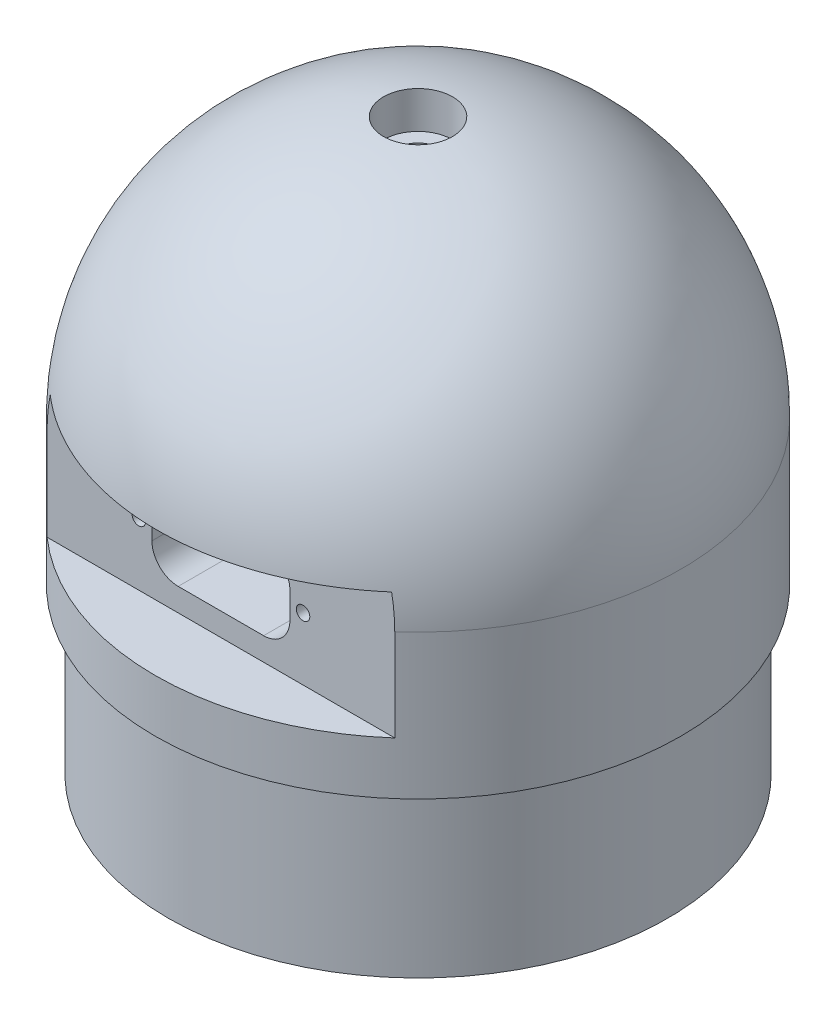
from build123d import *

# Parameters (mm, degrees)
ESQUISSE1_R                  = 40
BOSS_EXTRU_1_DEPTH           = 87
CONG_1_R                     = 40
ESQUISSE2_OUTSIDE_W          = 110.544
ESQUISSE2_OUTSIDE_H          = 110.544
ESQUISSE2_OUTSIDE_R          = 38
ENL_V_MAT_EXTRU_1_DEPTH      = 25
ENL_V_START                  = 40
ESQUISSE3_W                  = 76
ESQUISSE3_H                  = 19
ENL_V_MAT_EXTRU_2_DEPTH      = 10
ENL_V_MAT_EXTRU_3_DEPTH      = 20
ENL_V_MAT_EXTRU_4_DEPTH      = 68
ENL_V_MAT_EXTRU_5_REACH      = 21
ENL_V_MAT_EXTRU_5_END_RADIUS = 40
ESQUISSE6_R                  = 3.1
ESQUISSE8_R                  = 5.25
ENL_V_MAT_EXTRU_6_DEPTH      = 6
TROU_TARAUD_M2_51_D          = 2.05
TROU_TARAUD_M2_51_DEPTH      = 12
TROU_TARAUD_M51_REACH        = 25
TROU_TARAUD_M51_BORE_R       = 2.1


with BuildPart() as part:
    # Esquisse1 → Boss.-Extru.1 (new body)
    with BuildSketch(Plane(origin=(0, 0, 0), x_dir=(1, 0, 0), z_dir=(0, 1, 0))):
        with Locations(Location((0, 0, 0), (0, 0, 270))):  # turned: the seam where the file's is
            Circle(ESQUISSE1_R)
    extrude(amount=BOSS_EXTRU_1_DEPTH)

    # Congé1
    cong_1_edges = [part.edges().sort_by_distance(p)[0] for p in [
        (0, 87, -40),
    ]]
    fillet(cong_1_edges, radius=CONG_1_R)

    # Esquisse2 outside → Enlèv. mat.-Extru.1 (cut)
    with BuildSketch(Plane.XZ):
        Rectangle(ESQUISSE2_OUTSIDE_W, ESQUISSE2_OUTSIDE_H)
        with Locations(Location((0, 0, 0), (0, 0, 270))):  # turned: the seam where the file's is
            Circle(ESQUISSE2_OUTSIDE_R, mode=Mode.SUBTRACT)
    extrude(amount=-ENL_V_MAT_EXTRU_1_DEPTH, mode=Mode.SUBTRACT)

    # Esquisse3 → Enlèv. mat.-Extru.2 (cut)
    with BuildSketch(Plane.XY.offset(ENL_V_START)):
        with Locations((0, 42.5)):
            Rectangle(ESQUISSE3_W, ESQUISSE3_H)
    extrude(amount=-ENL_V_MAT_EXTRU_2_DEPTH, mode=Mode.SUBTRACT)

    # Esquisse4 → Enlèv. mat.-Extru.3 (cut)
    with BuildSketch(Plane.XY.offset(30)):
        with BuildLine():
            Line((-6.5, 36.5), (6.5, 36.5))
            ThreePointArc((6.5, 36.5), (9.328427125, 37.671572875), (10.5, 40.5))
            Line((10.5, 40.5), (10.5, 44.5))
            ThreePointArc((10.5, 44.5), (9.328427125, 47.328427125), (6.5, 48.5))
            Line((6.5, 48.5), (-6.5, 48.5))
            ThreePointArc((-6.5, 48.5), (-9.328427125, 47.328427125), (-10.5, 44.5))
            Line((-10.5, 44.5), (-10.5, 40.5))
            ThreePointArc((-10.5, 40.5), (-9.328427125, 37.671572875), (-6.5, 36.5))
        make_face()
    extrude(amount=-ENL_V_MAT_EXTRU_3_DEPTH, mode=Mode.SUBTRACT)

    # Esquisse5 → Enlèv. mat.-Extru.4 (cut)
    with BuildSketch(Plane.XZ):
        Polygon((-14, 18), (16, 18), (16, 22), (24, 22), (24, -22), (16, -22), (16, -18), (-14, -18), (-14, -20.5), (-17, -20.5), (-17, -18), (-27, -8), (-27, 8), (-17, 18), (-17, 20.5), (-14, 20.5), align=None)
    extrude(amount=-ENL_V_MAT_EXTRU_4_DEPTH, mode=Mode.SUBTRACT)

    # Enlèv. mat.-Extru.5: up to this sphere (the profile starts inside it)
    enl_v_mat_extru_5_end = Location((0, 47, 0)) * Sphere(ENL_V_MAT_EXTRU_5_END_RADIUS, mode=Mode.PRIVATE)
    # Esquisse6 → Enlèv. mat.-Extru.5 (cut, up to the surface)
    with BuildSketch(Plane.XZ.offset(-68), mode=Mode.PRIVATE) as enl_v_mat_extru_5_sk1:
        with Locations(Location((0, 0, 0), (0, 0, 270))):  # turned: the seam where the file's is
            Circle(ESQUISSE6_R)
    enl_v_mat_extru_5_tool1 = extrude(enl_v_mat_extru_5_sk1.sketch, amount=-ENL_V_MAT_EXTRU_5_REACH, mode=Mode.PRIVATE) & enl_v_mat_extru_5_end
    add(enl_v_mat_extru_5_tool1.solids().sort_by_distance((0, 68, 0))[0], mode=Mode.SUBTRACT)

    # Esquisse8 → Enlèv. mat.-Extru.6 (cut)
    with BuildSketch(Plane.XZ.offset(-87)):
        with Locations(Location((0, 0, 0), (0, 0, 270))):  # turned: the seam where the file's is
            Circle(ESQUISSE8_R)
    extrude(amount=ENL_V_MAT_EXTRU_6_DEPTH, mode=Mode.SUBTRACT)

    # Esquisse11 → Enlèvement de matière-Révolution1 (revolve, cut)
    with BuildSketch(Plane.XY, mode=Mode.PRIVATE) as enl_vement_de_mati_re_r_volution1_sk:
        Polygon((-27, 47), (-27, 41), (-45, 30.607695155), (-45, 47), align=None)
    revolve(enl_vement_de_mati_re_r_volution1_sk.sketch.rotate(Axis((-27, 47, 0), (-1, 0, 0)), 270), axis=Axis((-27, 47, 0), (-1, 0, 0)), mode=Mode.SUBTRACT)  # turned: the seam where the file's is

    # Trou taraudé M2.51
    with Locations(Plane.XY.offset(30)):
        with Locations((-12.5, 42.5), (12.5, 42.5)):
            Hole(TROU_TARAUD_M2_51_D / 2, depth=TROU_TARAUD_M2_51_DEPTH)

    # Trou taraudé M51 bore → Trou taraudé M51 (cut, up to next)
    with BuildSketch(Plane(origin=(-17, 0, 0), x_dir=(0, 0, -1), z_dir=(1, 0, 0)), mode=Mode.PRIVATE) as trou_taraud_m51_sk1:
        with Locations((14, 21)):
            Circle(TROU_TARAUD_M51_BORE_R)
    trou_taraud_m51_tool1 = extrude(trou_taraud_m51_sk1.sketch, amount=-TROU_TARAUD_M51_REACH, mode=Mode.PRIVATE) & part.part
    add(trou_taraud_m51_tool1.solids().sort_by_distance((-17, 21, -14))[0], mode=Mode.SUBTRACT)


solid = part.part
